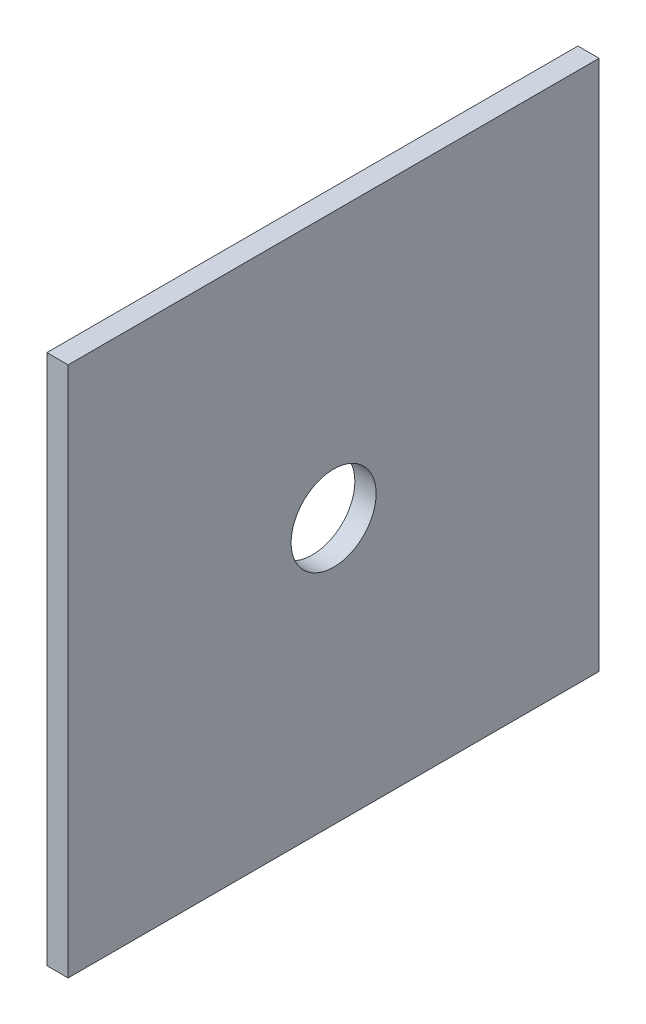
from build123d import *

# Parameters (mm, degrees)
SKETCH1_W           = 100
SKETCH1_H           = 100
SKETCH1_R           = 8
BOSS_EXTRUDE1_DEPTH = 2


with BuildPart() as part:
    # Sketch1 → Boss-Extrude1 (new body, symmetric)
    with BuildSketch(Plane(origin=(0, 0, 0), x_dir=(0, 0, -1), z_dir=(1, 0, 0))):
        Rectangle(SKETCH1_W, SKETCH1_H)
        Circle(SKETCH1_R, mode=Mode.SUBTRACT)
    extrude(amount=BOSS_EXTRUDE1_DEPTH, both=True)


solid = part.part
